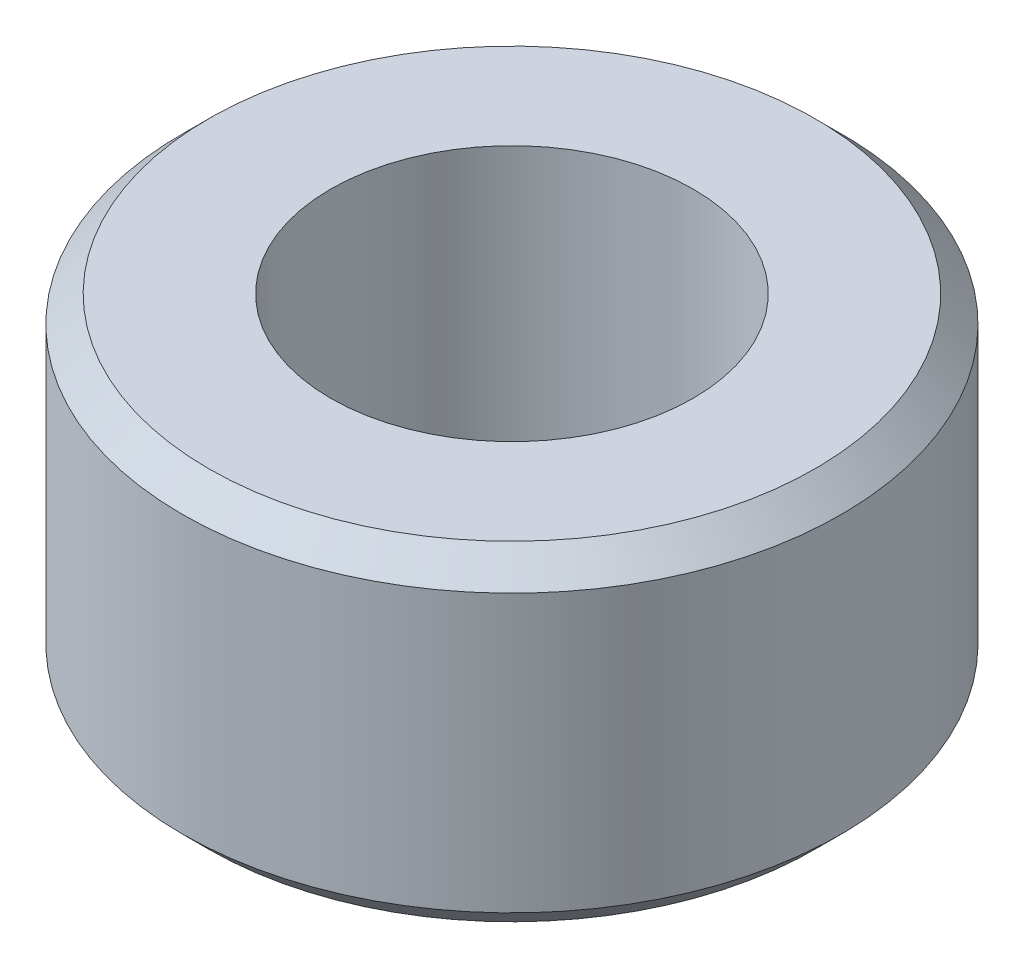
from build123d import *

# Parameters (mm, degrees)
SKETCH1_R           = 5
SKETCH1_R_2         = 2.75
BOSS_EXTRUDE1_DEPTH = 2.5
CHAMFER1_SIZE       = 0.4


with BuildPart() as part:
    # Sketch1 → Boss-Extrude1 (new body, symmetric)
    with BuildSketch(Plane(origin=(0, 0, 0), x_dir=(1, 0, 0), z_dir=(0, 1, 0))):
        Circle(SKETCH1_R)
        Circle(SKETCH1_R_2, mode=Mode.SUBTRACT)
    extrude(amount=BOSS_EXTRUDE1_DEPTH, both=True)

    # Chamfer1
    chamfer1_edges = [part.edges().sort_by_distance(p)[0] for p in [
        (-5, -2.5, 0),
        (-5, 2.5, 0),
    ]]
    chamfer(chamfer1_edges, length=CHAMFER1_SIZE)


solid = part.part
